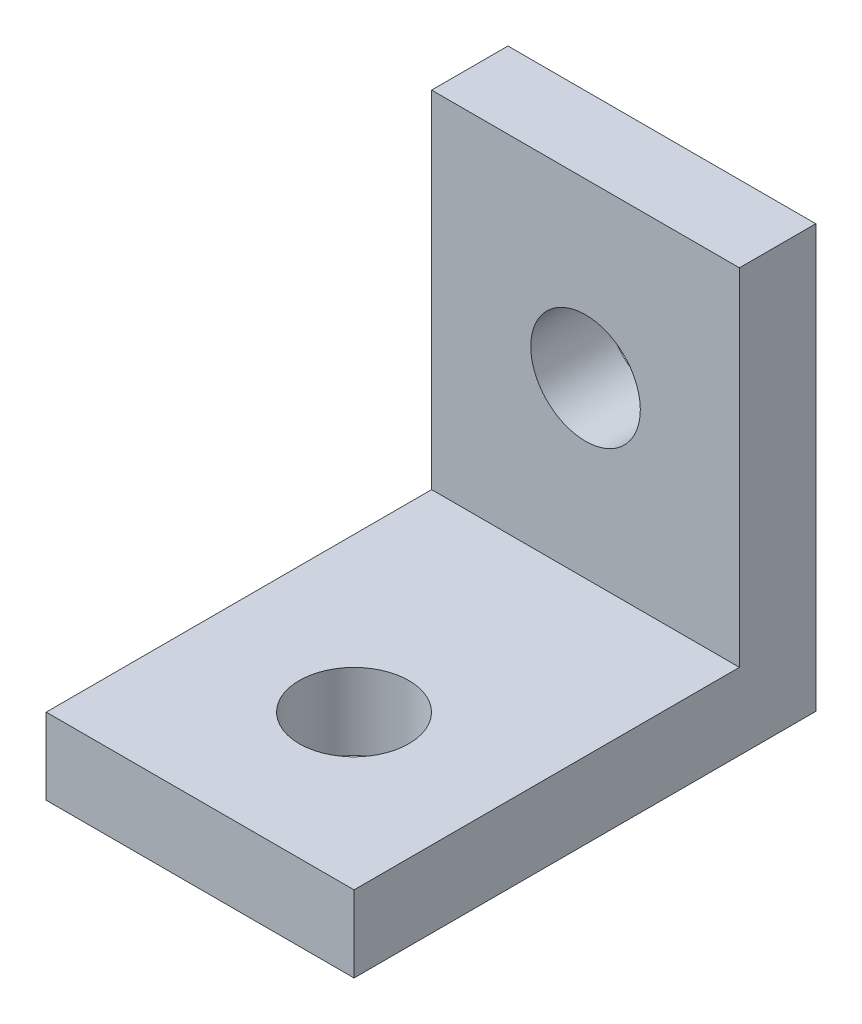
from build123d import *

# Parameters (mm, degrees)
SKETCH1_W           = 6.35
SKETCH1_H           = 9.525
BOSS_EXTRUDE1_DEPTH = 1.5748
SKETCH2_R           = 1.1303
CUT_EXTRUDE1_DEPTH  = 2.5748
SKETCH3_W           = 6.35
SKETCH3_H           = 1.5748
BOSS_EXTRUDE2_DEPTH = 7.1374
SKETCH4_R           = 1.1303
CUT_EXTRUDE2_DEPTH  = 2.5748


with BuildPart() as part:
    # Sketch1 → Boss-Extrude1 (new body)
    with BuildSketch(Plane(origin=(0, 0, 0), x_dir=(1, 0, 0), z_dir=(0, 1, 0))):
        Rectangle(SKETCH1_W, SKETCH1_H)
    extrude(amount=BOSS_EXTRUDE1_DEPTH)

    # Sketch2 → Cut-Extrude1 (cut, through all)
    with BuildSketch(Plane(origin=(0, 1.5748, 0), x_dir=(1, 0, 0), z_dir=(0, 1, 0))):
        with Locations((0, -1.5875)):
            Circle(SKETCH2_R)
    extrude(amount=-CUT_EXTRUDE1_DEPTH, mode=Mode.SUBTRACT)

    # Sketch3 → Boss-Extrude2 (add)
    with BuildSketch(Plane(origin=(0, 1.5748, 0), x_dir=(1, 0, 0), z_dir=(0, 1, 0))):
        with Locations((0, 3.9751)):
            Rectangle(SKETCH3_W, SKETCH3_H)
    extrude(amount=BOSS_EXTRUDE2_DEPTH)

    # Sketch4 → Cut-Extrude2 (cut, through all)
    with BuildSketch(Plane.XY.offset(-3.1877)):
        with Locations((0, 5.1562)):
            Circle(SKETCH4_R)
    extrude(amount=-CUT_EXTRUDE2_DEPTH, mode=Mode.SUBTRACT)


solid = part.part
